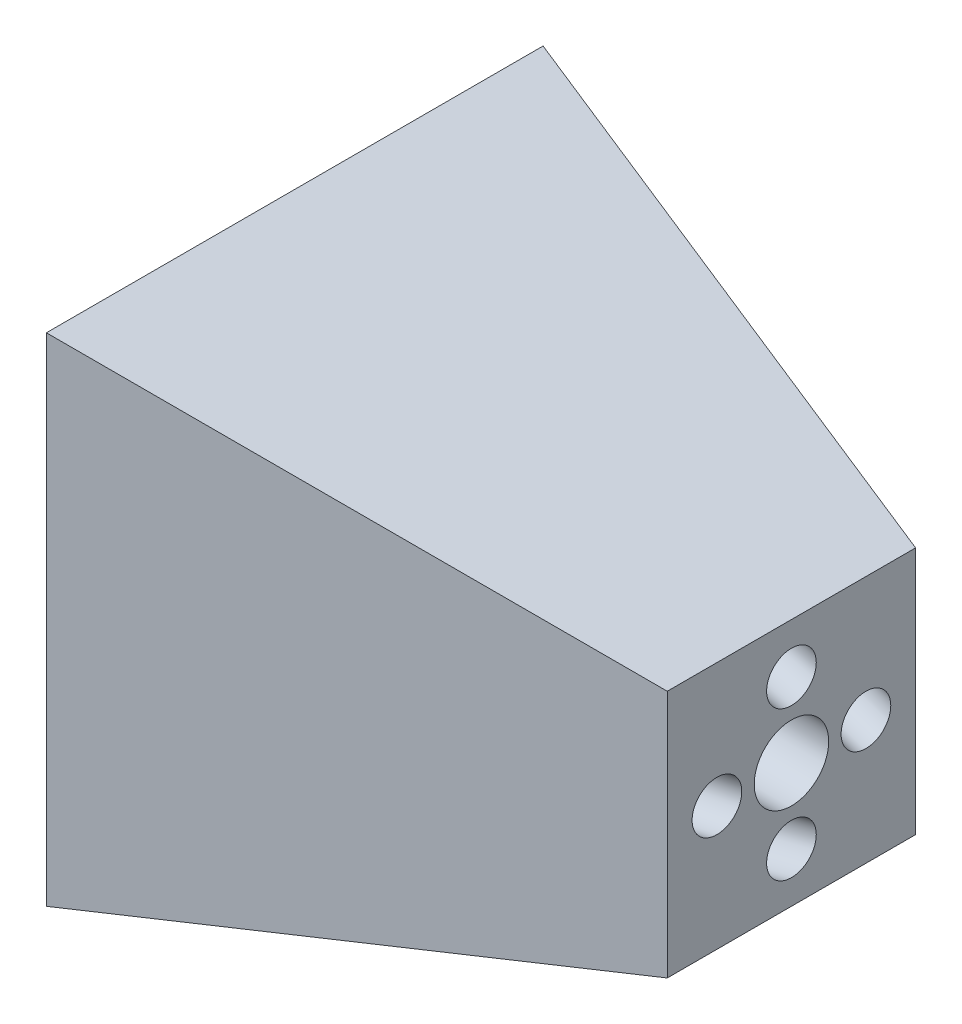
from build123d import *

# Parameters (mm, degrees)
SKETCH1_W          = 50
SKETCH1_H          = 50
SKETCH2_W          = 100
SKETCH2_H          = 100
SKETCH3_R          = 5
SKETCH6_R          = 5
SKETCH7_R          = 7.5
CUT_EXTRUDE1_DEPTH = 101.0000001


with BuildPart() as part:
    # Sketch1 → Loft1 section 0
    with BuildSketch(Plane(origin=(0, 0, 0), x_dir=(0, 0, -1), z_dir=(1, 0, 0))):
        Rectangle(SKETCH1_W, SKETCH1_H)
    # Sketch2 → Loft1 section 1
    with BuildSketch(Plane(origin=(-100, 0, 0), x_dir=(0, 0, -1), z_dir=(1, 0, 0))):
        Rectangle(SKETCH2_W, SKETCH2_H)
    loft()

    # Cut-Sweep2: sweep along a path in Sketch4
    with BuildLine(Plane(origin=(0, 0, 0), x_dir=(1, 0, 0), z_dir=(0, 1, 0))) as cut_sweep2_path:
        Line((0, 15), (-100, 40))
    # Sketch3 → Cut-Sweep2 (sweep, cut)
    with BuildSketch(Plane(origin=(0, 0, 0), x_dir=(0, 0, -1), z_dir=(1, 0, 0))):
        with Locations((15, 0)):
            Circle(SKETCH3_R)
    cut_sweep2 = sweep(path=cut_sweep2_path.line, mode=Mode.SUBTRACT)

    # Cut-Sweep3: sweep along a path in Sketch5
    with BuildLine(Plane.XY) as cut_sweep3_path:
        Line((0, 15), (-100, 40))
    # Sketch6 → Cut-Sweep3 (sweep, cut)
    with BuildSketch(Plane(origin=(0, 0, 0), x_dir=(0, 0, -1), z_dir=(1, 0, 0))):
        with Locations((0, 15)):
            Circle(SKETCH6_R)
    cut_sweep3 = sweep(path=cut_sweep3_path.line, mode=Mode.SUBTRACT)

    # Mirror1: Cut-Sweep2 across plane
    add(cut_sweep2.mirror(Plane.XY), mode=Mode.SUBTRACT)

    # Mirror2: Cut-Sweep3 across plane
    add(cut_sweep3.mirror(Plane.ZX), mode=Mode.SUBTRACT)

    # Sketch7 → Cut-Extrude1 (cut, through all)
    with BuildSketch(Plane(origin=(0, 0, 0), x_dir=(0, 0, -1), z_dir=(1, 0, 0))):
        Circle(SKETCH7_R)
    extrude(amount=-CUT_EXTRUDE1_DEPTH, mode=Mode.SUBTRACT)


solid = part.part
